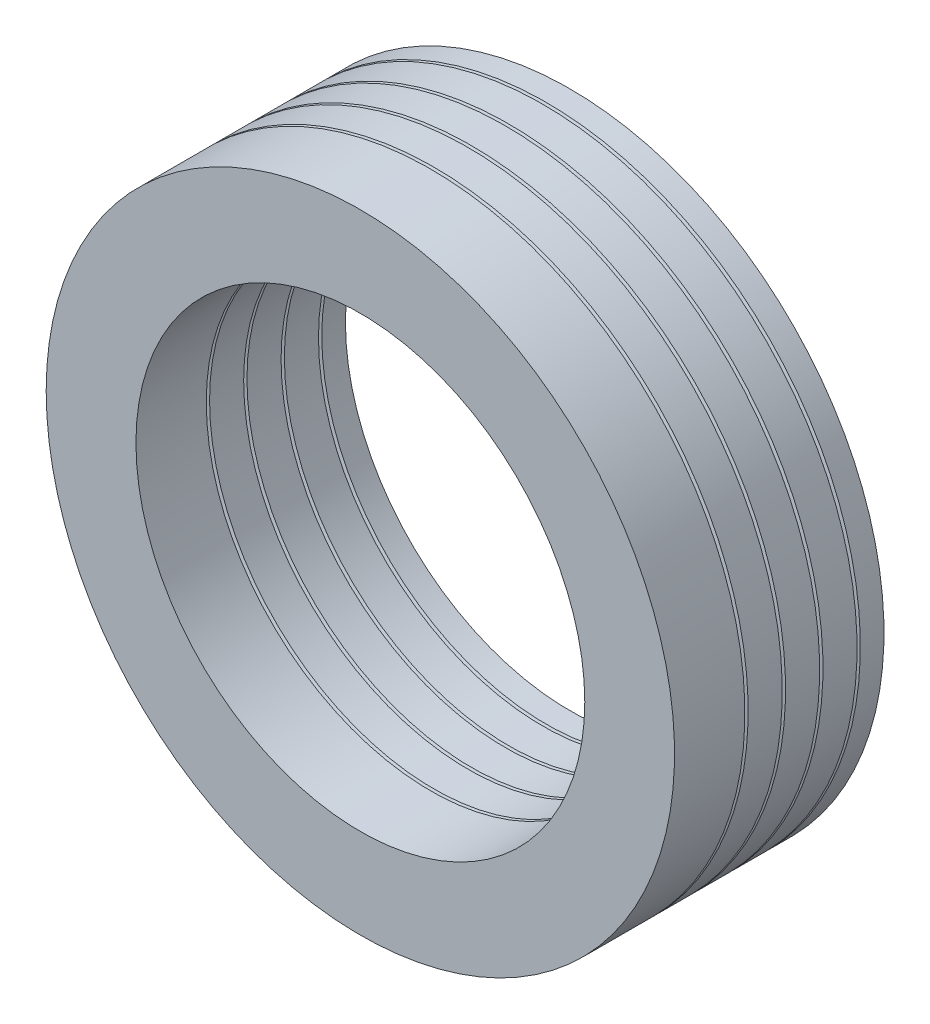
from build123d import *


with BuildPart() as part:
    # Sketch4 → Revolve1 (revolve)
    with BuildSketch(Plane(origin=(0, 0, 0), x_dir=(1, 0, 0), z_dir=(0, 1, 0))):
        Polygon((-15, 0.004793102), (-21, 0.004793102), (-21, 4.704793102), (-18.5, 3.501086914), (-18.5, 3.106819455), (-17.5, 3.106819455), (-17.5, 3.501086914), (-15, 4.704793102), align=None)
        Polygon((-15, 14.004793102), (-17.5, 14.004793102), (-17.5, 13.614793102), (-18.5, 13.614793102), (-18.5, 14.004793102), (-21, 14.004793102), (-21, 12.424793102), (-18, 10.980345677), (-15, 12.424793102), align=None)
        Polygon((-17.5, 11.001086914), (-15, 12.204793102), (-15, 9.924793102), (-18, 8.480345677), (-21, 9.924793102), (-21, 12.204793102), (-18.5, 11.001086914), (-18.5, 10.606819455), (-17.5, 10.606819455), align=None)
        Polygon((-21, 9.704793102), (-18.5, 8.501086914), (-18.5, 8.106819455), (-17.5, 8.106819455), (-17.5, 8.501086914), (-15, 9.704793102), (-15, 7.424793102), (-18, 5.980345677), (-21, 7.424793102), align=None)
        Polygon((-21, 7.204793102), (-18.5, 6.001086914), (-18.5, 5.606819455), (-17.5, 5.606819455), (-17.5, 6.001086914), (-15, 7.204793102), (-15, 4.924793102), (-18, 3.480345677), (-21, 4.924793102), align=None)
    revolve(axis=Axis((0, 0, -102.328960849), (0, 0, 1)))


solid = part.part
